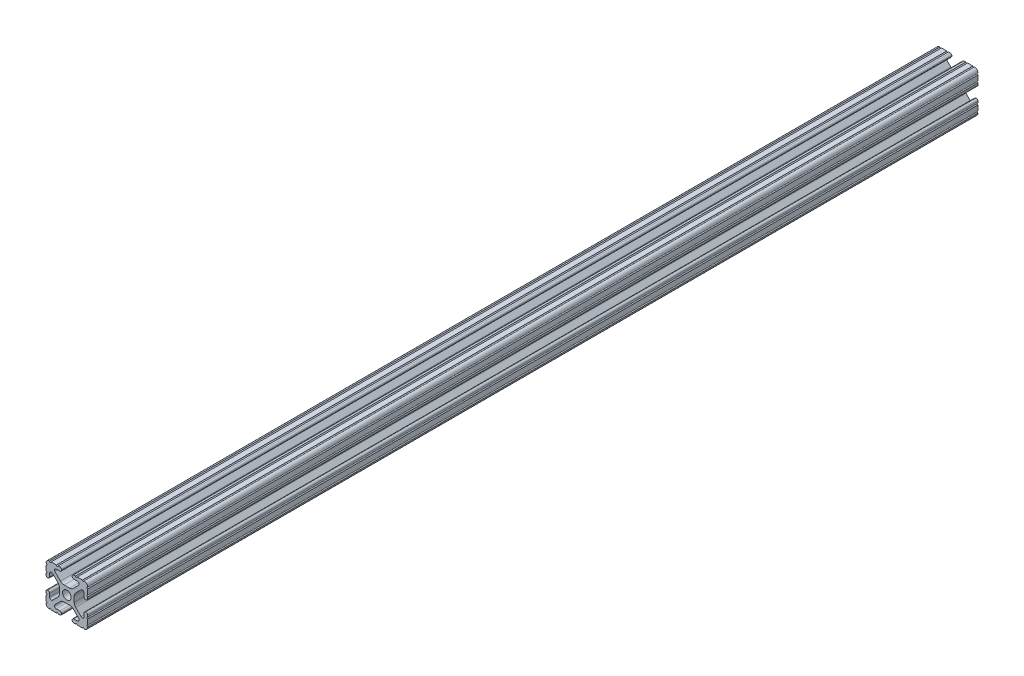
from build123d import *

# Parameters (mm, degrees)
SKETCH1_R      = 2.6035
EXTRUDE1_DEPTH = 542.925


with BuildPart() as part:
    # Sketch1 → Extrude1 (new body)
    with BuildSketch(Plane.XY):
        with BuildLine():
            Line((-7.207036008, 8.724370562), (-3.898272566, 5.423169045))
            ThreePointArc((-3.898272566, 5.423169045), (-2.869120213, 4.736787962), (-1.655778399, 4.4958))
            Line((-1.655778399, 4.4958), (1.655778399, 4.4958))
            ThreePointArc((1.655778399, 4.4958), (2.869120213, 4.736787962), (3.898272566, 5.423169045))
            Line((3.898272566, 5.423169045), (7.207036008, 8.724370562))
            ThreePointArc((7.207036008, 8.724370562), (7.432222385, 9.85140422), (6.476788598, 10.4902))
            Line((6.476788598, 10.4902), (4.287512407, 10.4902))
            ThreePointArc((4.287512407, 10.4902), (3.54574862, 10.79744862), (3.2385, 11.539212407))
            Line((3.2385, 11.539212407), (3.2385, 11.650987593))
            ThreePointArc((3.2385, 11.650987593), (3.54574862, 12.39275138), (4.287512407, 12.7))
            Line((4.287512407, 12.7), (5.317126718, 12.7))
            ThreePointArc((5.317126718, 12.7), (5.825126718, 12.192), (6.333126718, 12.7))
            Line((6.333126718, 12.7), (9.550443118, 12.7))
            ThreePointArc((9.550443118, 12.7), (10.058366869, 12.192000006), (10.566443095, 12.699847501))
            ThreePointArc((10.566443095, 12.699847501), (12.082537762, 12.08250727), (12.699846982, 10.566399977))
            ThreePointArc((12.699846982, 10.566399977), (12.192000006, 10.058323491), (12.7, 9.5504))
            Line((12.7, 9.5504), (12.7, 6.3330836))
            ThreePointArc((12.7, 6.3330836), (12.192, 5.8250836), (12.7, 5.3170836))
            Line((12.7, 5.3170836), (12.7, 4.287469289))
            ThreePointArc((12.7, 4.287469289), (12.39275138, 3.545705502), (11.650987593, 3.238456882))
            Line((11.650987593, 3.238456882), (11.539212407, 3.238456882))
            ThreePointArc((11.539212407, 3.238456882), (10.79744862, 3.545705502), (10.4902, 4.287469289))
            Line((10.4902, 4.287469289), (10.4902, 6.402089023))
            ThreePointArc((10.4902, 6.402089023), (9.856505071, 7.351067942), (8.737131347, 7.129408934))
            Line((8.737131347, 7.129408934), (5.441005833, 3.840816462))
            ThreePointArc((5.441005833, 3.840816462), (4.750877967, 2.809883091), (4.5085, 1.593185507))
            Line((4.5085, 1.593185507), (4.5085, -1.593185507))
            ThreePointArc((4.5085, -1.593185507), (4.750877967, -2.809883091), (5.441005833, -3.840816462))
            Line((5.441005833, -3.840816462), (8.737131347, -7.129408934))
            ThreePointArc((8.737131347, -7.129408934), (9.856505071, -7.351067942), (10.4902, -6.402089023))
            Line((10.4902, -6.402089023), (10.4902, -4.287469289))
            ThreePointArc((10.4902, -4.287469289), (10.79744862, -3.545705502), (11.539212407, -3.238456882))
            Line((11.539212407, -3.238456882), (11.650987593, -3.238456882))
            ThreePointArc((11.650987593, -3.238456882), (12.39275138, -3.545705502), (12.7, -4.287469289))
            Line((12.7, -4.287469289), (12.7, -5.3170836))
            ThreePointArc((12.7, -5.3170836), (12.192, -5.8250836), (12.7, -6.3330836))
            Line((12.7, -6.3330836), (12.7, -9.5504))
            ThreePointArc((12.7, -9.5504), (12.192000006, -10.058323491), (12.699846982, -10.566399977))
            ThreePointArc((12.699846982, -10.566399977), (12.082537762, -12.08250727), (10.566443095, -12.699847501))
            ThreePointArc((10.566443095, -12.699847501), (10.058366869, -12.192000006), (9.550443118, -12.7))
            Line((9.550443118, -12.7), (6.333126718, -12.7))
            ThreePointArc((6.333126718, -12.7), (5.825126718, -12.192), (5.317126718, -12.7))
            Line((5.317126718, -12.7), (4.287512407, -12.7))
            ThreePointArc((4.287512407, -12.7), (3.54574862, -12.39275138), (3.2385, -11.650987593))
            Line((3.2385, -11.650987593), (3.2385, -11.539212407))
            ThreePointArc((3.2385, -11.539212407), (3.54574862, -10.79744862), (4.287512407, -10.4902))
            Line((4.287512407, -10.4902), (6.416408329, -10.4902))
            ThreePointArc((6.416408329, -10.4902), (7.41473083, -9.822813117), (7.179650497, -8.645192506))
            Line((7.179650497, -8.645192506), (3.952270251, -5.423690499))
            ThreePointArc((3.952270251, -5.423690499), (2.922936451, -4.736929036), (1.709253557, -4.4958))
            Line((1.709253557, -4.4958), (-1.709253557, -4.4958))
            ThreePointArc((-1.709253557, -4.4958), (-2.922936451, -4.736929036), (-3.952270251, -5.423690499))
            Line((-3.952270251, -5.423690499), (-7.179650497, -8.645192506))
            ThreePointArc((-7.179650497, -8.645192506), (-7.41473083, -9.822813117), (-6.416408329, -10.4902))
            Line((-6.416408329, -10.4902), (-4.287512407, -10.4902))
            ThreePointArc((-4.287512407, -10.4902), (-3.54574862, -10.79744862), (-3.2385, -11.539212407))
            Line((-3.2385, -11.539212407), (-3.2385, -11.650987593))
            ThreePointArc((-3.2385, -11.650987593), (-3.54574862, -12.39275138), (-4.287512407, -12.7))
            Line((-4.287512407, -12.7), (-5.317126718, -12.7))
            ThreePointArc((-5.317126718, -12.7), (-5.825126718, -12.192), (-6.333126718, -12.7))
            Line((-6.333126718, -12.7), (-9.550443118, -12.7))
            ThreePointArc((-9.550443118, -12.7), (-10.058366869, -12.192000006), (-10.566443095, -12.699847501))
            ThreePointArc((-10.566443095, -12.699847501), (-12.082537762, -12.08250727), (-12.699846982, -10.566399977))
            ThreePointArc((-12.699846982, -10.566399977), (-12.192000006, -10.058323491), (-12.7, -9.5504))
            Line((-12.7, -9.5504), (-12.7, -6.3330836))
            ThreePointArc((-12.7, -6.3330836), (-12.192, -5.8250836), (-12.7, -5.3170836))
            Line((-12.7, -5.3170836), (-12.7, -4.287469289))
            ThreePointArc((-12.7, -4.287469289), (-12.39275138, -3.545705502), (-11.650987593, -3.238456882))
            Line((-11.650987593, -3.238456882), (-11.539212407, -3.238456882))
            ThreePointArc((-11.539212407, -3.238456882), (-10.79744862, -3.545705502), (-10.4902, -4.287469289))
            Line((-10.4902, -4.287469289), (-10.4902, -6.402089023))
            ThreePointArc((-10.4902, -6.402089023), (-9.856505071, -7.351067942), (-8.737131347, -7.129408934))
            Line((-8.737131347, -7.129408934), (-5.441005833, -3.840816462))
            ThreePointArc((-5.441005833, -3.840816462), (-4.750877967, -2.809883091), (-4.5085, -1.593185507))
            Line((-4.5085, -1.593185507), (-4.5085, 1.593185507))
            ThreePointArc((-4.5085, 1.593185507), (-4.750877967, 2.809883091), (-5.441005833, 3.840816462))
            Line((-5.441005833, 3.840816462), (-8.737131347, 7.129408934))
            ThreePointArc((-8.737131347, 7.129408934), (-9.856505071, 7.351067942), (-10.4902, 6.402089023))
            Line((-10.4902, 6.402089023), (-10.4902, 4.287469289))
            ThreePointArc((-10.4902, 4.287469289), (-10.79744862, 3.545705502), (-11.539212407, 3.238456882))
            Line((-11.539212407, 3.238456882), (-11.650987593, 3.238456882))
            ThreePointArc((-11.650987593, 3.238456882), (-12.39275138, 3.545705502), (-12.7, 4.287469289))
            Line((-12.7, 4.287469289), (-12.7, 5.3170836))
            ThreePointArc((-12.7, 5.3170836), (-12.192, 5.8250836), (-12.7, 6.3330836))
            Line((-12.7, 6.3330836), (-12.7, 9.5504))
            ThreePointArc((-12.7, 9.5504), (-12.192000006, 10.058323491), (-12.699846982, 10.566399977))
            ThreePointArc((-12.699846982, 10.566399977), (-12.082537762, 12.08250727), (-10.566443095, 12.699847501))
            ThreePointArc((-10.566443095, 12.699847501), (-10.058366869, 12.192000006), (-9.550443118, 12.7))
            Line((-9.550443118, 12.7), (-6.333126718, 12.7))
            ThreePointArc((-6.333126718, 12.7), (-5.825126718, 12.192), (-5.317126718, 12.7))
            Line((-5.317126718, 12.7), (-4.287512407, 12.7))
            ThreePointArc((-4.287512407, 12.7), (-3.54574862, 12.39275138), (-3.2385, 11.650987593))
            Line((-3.2385, 11.650987593), (-3.2385, 11.539212407))
            ThreePointArc((-3.2385, 11.539212407), (-3.54574862, 10.79744862), (-4.287512407, 10.4902))
            Line((-4.287512407, 10.4902), (-6.476788598, 10.4902))
            ThreePointArc((-6.476788598, 10.4902), (-7.432222385, 9.85140422), (-7.207036008, 8.724370562))
        make_face()
        Circle(SKETCH1_R, mode=Mode.SUBTRACT)
    extrude(amount=-EXTRUDE1_DEPTH)


solid = part.part
